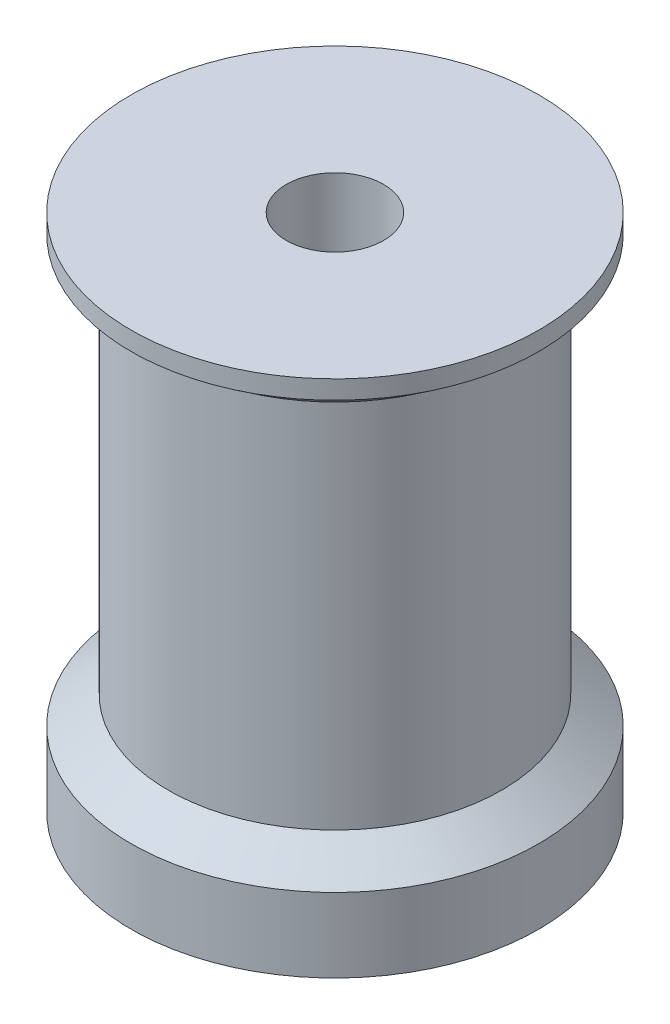
from build123d import *


with BuildPart() as part:
    # Sketch1 → Revolve1 (revolve)
    with BuildSketch(Plane.XY):
        Polygon((-2.625, 0), (-2.625, 28), (-11, 28), (-11, 27), (-9, 25.5), (-9, 5.5), (-11, 4), (-11, 0), align=None)
    revolve(axis=Axis((0, 0, 0), (0, 1, 0)))


solid = part.part
